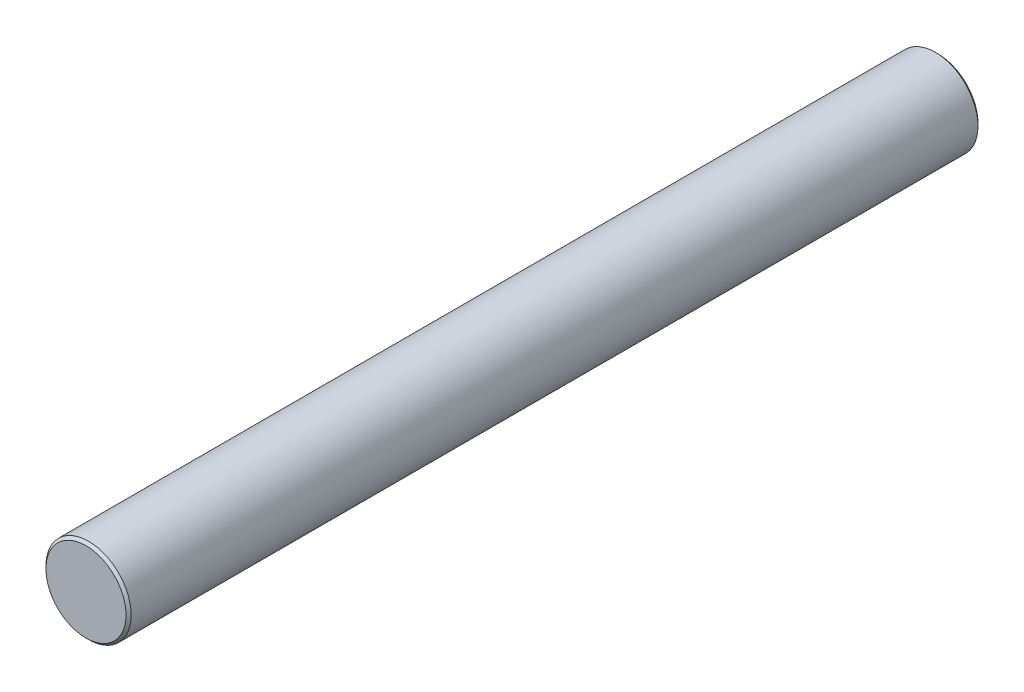
from build123d import *

# Parameters (mm, degrees)
SKETCH1_R           = 5
BOSS_EXTRUDE1_DEPTH = 50
CHAMFER1_SIZE       = 0.3


with BuildPart() as part:
    # Sketch1 → Boss-Extrude1 (new body, symmetric)
    with BuildSketch(Plane.XY):
        Circle(SKETCH1_R)
    extrude(amount=BOSS_EXTRUDE1_DEPTH, both=True)

    # Chamfer1
    chamfer1_edges = [part.edges().sort_by_distance(p)[0] for p in [
        (-5, 0, -50),
        (-5, 0, 50),
    ]]
    chamfer(chamfer1_edges, length=CHAMFER1_SIZE)


solid = part.part
